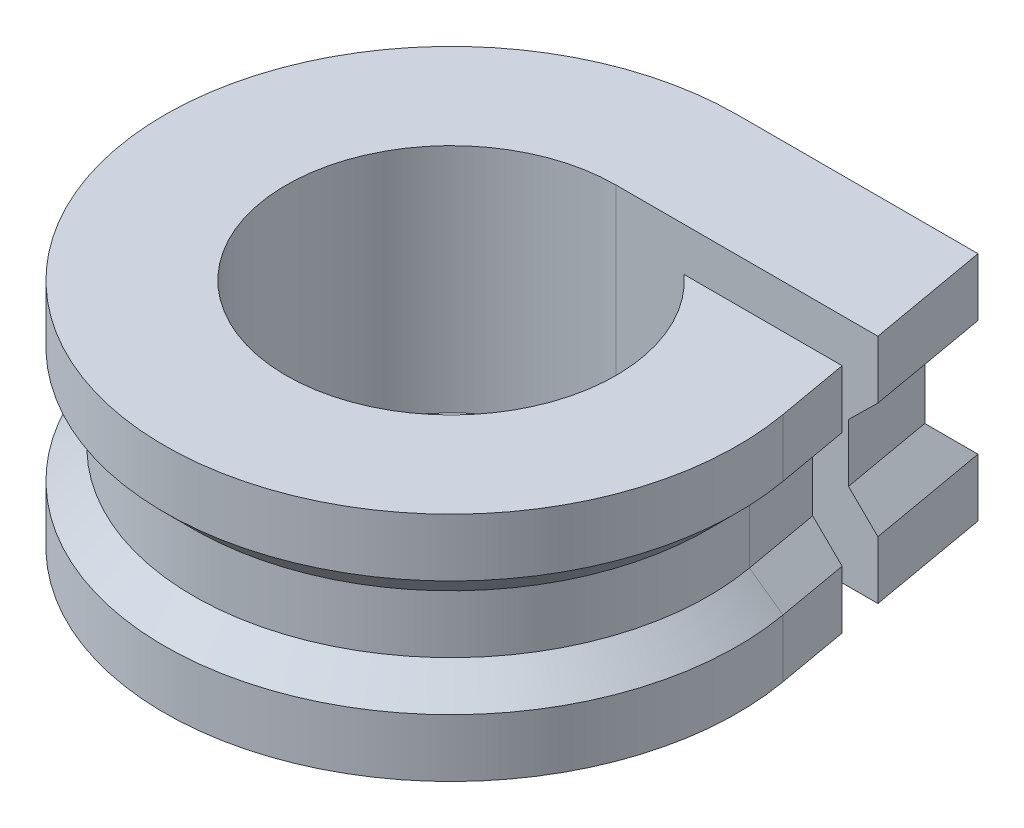
from build123d import *

# Parameters (mm, degrees)
BOSS_EXTRUDE1_DEPTH = 3
CHAMFER1_SIZE       = 1
BOSS_EXTRUDE2_DEPTH = 1


with BuildPart() as part:
    # Sketch1 → Boss-Extrude1 (new body)
    with BuildSketch(Plane(origin=(0, 0, 0), x_dir=(1, 0, 0), z_dir=(0, 1, 0))):
        with BuildLine():
            Line((8.307086349, 9.9), (0, 9.9))
            ThreePointArc((0, 9.9), (-6.363597336, -7.583839987), (9.749596755, 1.719116959))
            Line((9.749596755, 1.719116959), (9.312150139, 4.2))
            Line((9.312150139, 4.2), (3.853569774, 4.2))
            ThreePointArc((3.853569774, 4.2), (5.218014359, 2.293976056), (5.7, 0))
            ThreePointArc((5.7, 0), (-4.030508653, -4.030508653), (0, 5.7))
            Line((0, 5.7), (9.047659668, 5.7))
            Line((9.047659668, 5.7), (8.307086349, 9.9))
        make_face()
    extrude(amount=BOSS_EXTRUDE1_DEPTH)

    # Chamfer1
    chamfer1_edges = [part.edges().sort_by_distance(p)[0] for p in [
        (-6.363597336, 3, 7.583839987),
        (9.530873447, 3, -2.959558479),
        (8.677373008, 3, -7.8),
        (4.153543174, 3, -9.9),
    ]]
    chamfer(chamfer1_edges, length=CHAMFER1_SIZE)

    # Sketch3 → Boss-Extrude2 (add)
    with BuildSketch(Plane(origin=(0, 3, 0), x_dir=(1, 0, 0), z_dir=(0, 1, 0))):
        with BuildLine():
            Line((0, 5.7), (8.032233056, 5.7))
            Line((8.032233056, 5.7), (7.467986717, 8.9))
            Line((7.467986717, 8.9), (0, 8.9))
            ThreePointArc((0, 8.9), (-5.720809726, -6.817795544), (8.764789002, 1.545468781))
            Line((8.764789002, 1.545468781), (8.296723527, 4.2))
            Line((8.296723527, 4.2), (3.853569774, 4.2))
            ThreePointArc((3.853569774, 4.2), (-2.067607313, -5.311779363), (0, 5.7))
        make_face()
    extrude(amount=BOSS_EXTRUDE2_DEPTH)

    # Mirror1: part across plane


with BuildPart() as part_1:
    add(part.part)
    add(part.part.mirror(Plane.ZX.offset(4)))


solid = part_1.part
